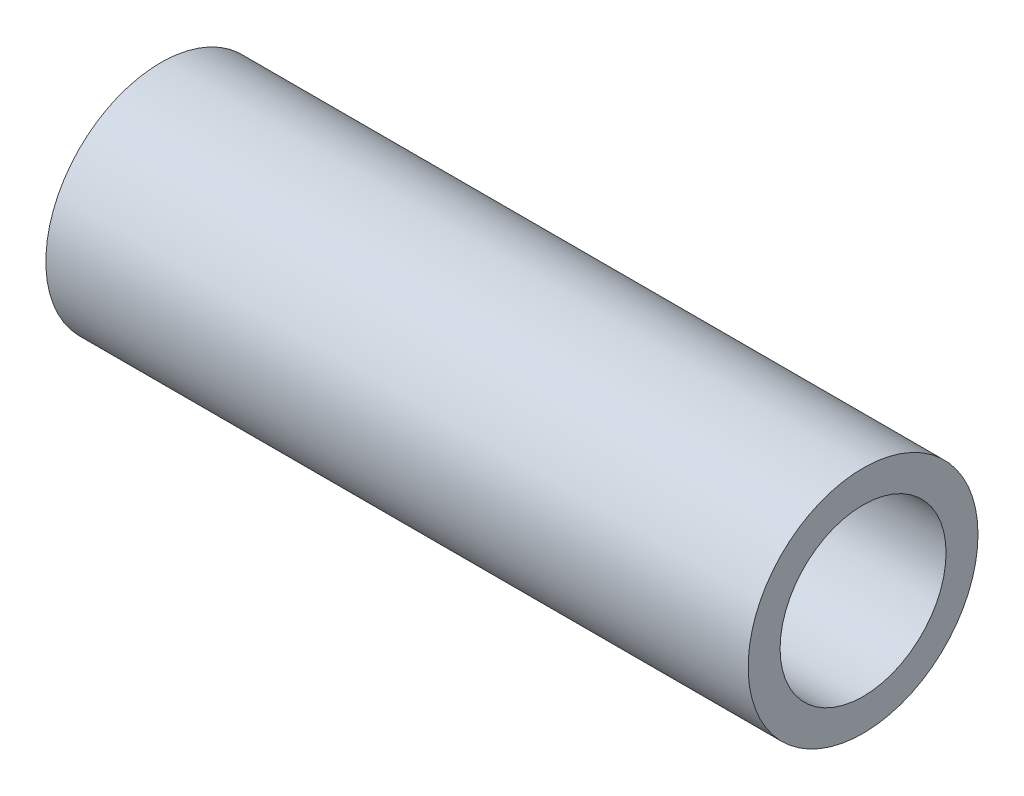
from build123d import *

# Parameters (mm, degrees)
SKETCH2_R           = 9
SKETCH2_R_2         = 6.5
BOSS_EXTRUDE1_DEPTH = 27.5


with BuildPart() as part:
    # Sketch2 → Boss-Extrude1 (new body, symmetric)
    with BuildSketch(Plane(origin=(0, 0, 0), x_dir=(0, 0, -1), z_dir=(1, 0, 0))):
        Circle(SKETCH2_R)
        Circle(SKETCH2_R_2, mode=Mode.SUBTRACT)
    extrude(amount=BOSS_EXTRUDE1_DEPTH, both=True)


solid = part.part
